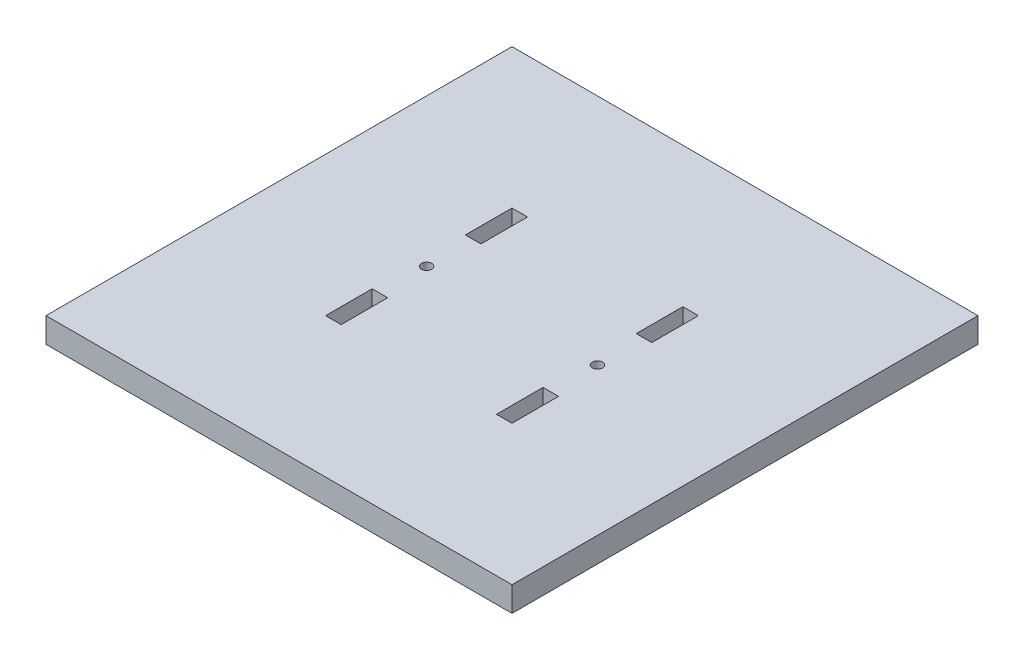
from build123d import *

# Parameters (mm, degrees)
SKETCH1_W           = 150
SKETCH1_H           = 150
SKETCH1_R           = 1.65
SKETCH1_W_2         = 5
SKETCH1_H_2         = 15
BOSS_EXTRUDE1_DEPTH = 8


with BuildPart() as part:
    # Sketch1 → Boss-Extrude1 (new body)
    with BuildSketch(Plane(origin=(0, 0, 0), x_dir=(1, 0, 0), z_dir=(0, 1, 0))):
        with Locations((75, 75)):
            Rectangle(SKETCH1_W, SKETCH1_H)
        with Locations((102.5, 75)):
            Circle(SKETCH1_R, mode=Mode.SUBTRACT)
        with Locations((47.5, 75)):
            Circle(SKETCH1_R, mode=Mode.SUBTRACT)
        with Locations((102.5, 52.5)):
            Rectangle(SKETCH1_W_2, SKETCH1_H_2, mode=Mode.SUBTRACT)
        with Locations((102.5, 97.5)):
            Rectangle(SKETCH1_W_2, SKETCH1_H_2, mode=Mode.SUBTRACT)
        with Locations((47.5, 52.5)):
            Rectangle(SKETCH1_W_2, SKETCH1_H_2, mode=Mode.SUBTRACT)
        with Locations((47.5, 97.5)):
            Rectangle(SKETCH1_W_2, SKETCH1_H_2, mode=Mode.SUBTRACT)
    extrude(amount=BOSS_EXTRUDE1_DEPTH)


solid = part.part
